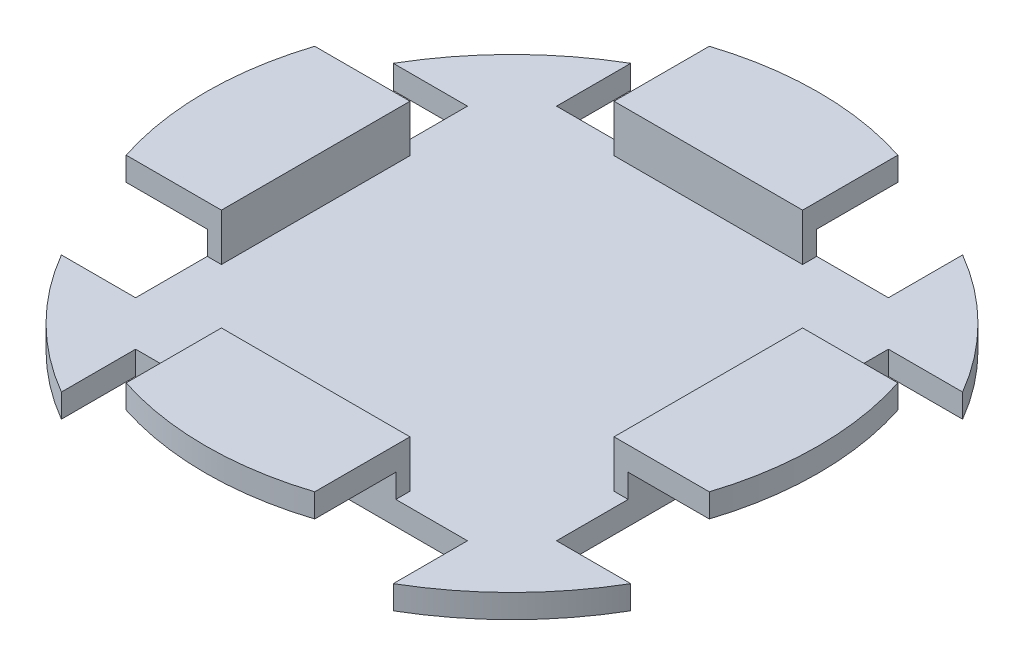
from build123d import *

# Parameters (mm, degrees)
SKETCH1_R         = 88.773
BASE_DEPTH        = 6.35
STOPPER_DEPTH     = 12.7
STOPPER_START     = -6.35
STOPPER_GAP_DEPTH = 13.7
CIRPATTERN1_COUNT = 4


with BuildPart() as part:
    # Sketch1 → Base (new body)
    with BuildSketch(Plane(origin=(0, 0, 0), x_dir=(1, 0, 0), z_dir=(0, 1, 0))):
        Circle(SKETCH1_R)
    extrude(amount=BASE_DEPTH)

    # Sketch2 → Stopper (add)
    with BuildSketch(Plane(origin=(0, 6.35, 0), x_dir=(1, 0, 0), z_dir=(0, 1, 0))):
        with BuildLine():
            Line((-25.4, -78.545162168), (-25.4, -52.891162168))
            Line((-25.4, -52.891162168), (0, -52.891162168))
            Line((0, -52.891162168), (25.4, -52.891162168))
            Line((25.4, -52.891162168), (25.4, -78.545162168))
            ThreePointArc((25.4, -78.545162168), (12.856892374, -81.542644172), (0, -82.55))
            ThreePointArc((0, -82.55), (-12.856892374, -81.542644172), (-25.4, -78.545162168))
        make_face()
    stopper = extrude(amount=STOPPER_DEPTH)

    # Sketch5 → Stopper Gap (cut, through all)
    with BuildSketch(Plane(origin=(0, 19.05, 0), x_dir=(1, 0, 0), z_dir=(0, 1, 0)).offset(STOPPER_START)):
        with BuildLine():
            Line((-44.704, -76.695488218), (-44.704, -56.701162168))
            Line((-44.704, -56.701162168), (0, -56.701162168))
            Line((0, -56.701162168), (44.704, -56.701162168))
            Line((44.704, -56.701162168), (44.704, -76.695488218))
            ThreePointArc((44.704, -76.695488218), (23.153368582, -85.700449545), (0, -88.773))
            ThreePointArc((0, -88.773), (-23.153368582, -85.700449545), (-44.704, -76.695488218))
        make_face()
    stopper_gap = extrude(amount=-STOPPER_GAP_DEPTH, mode=Mode.SUBTRACT)

    # CirPattern1: Stopper, Stopper Gap ×4 about axis
    cirpattern1_axis = Axis((0, 0, 0), (0, 1, 0))
    for i in range(1, CIRPATTERN1_COUNT):
        add(stopper.rotate(cirpattern1_axis, i * 360 / CIRPATTERN1_COUNT))
        add(stopper_gap.rotate(cirpattern1_axis, i * 360 / CIRPATTERN1_COUNT), mode=Mode.SUBTRACT)


solid = part.part
